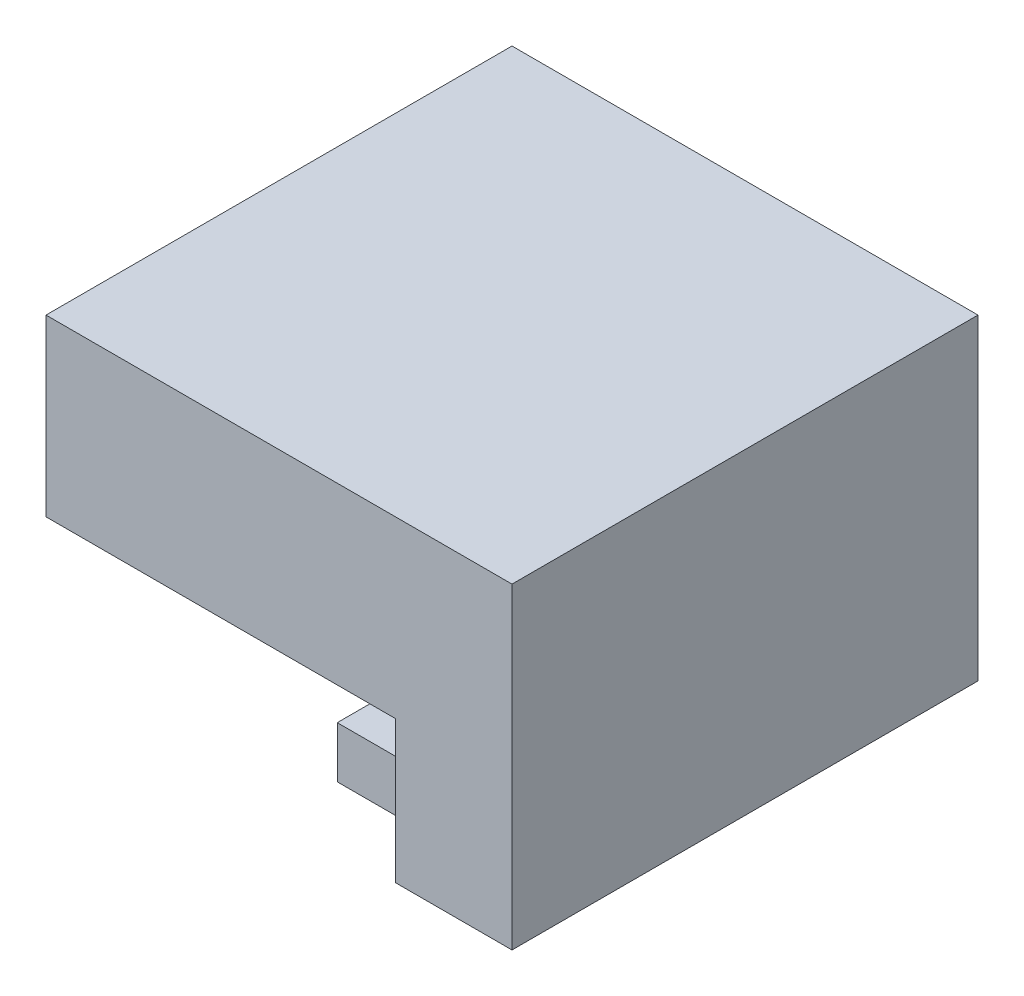
from build123d import *

# Parameters (mm, degrees)
SKETCH1_W           = 25.4
SKETCH1_H           = 9.525
BOSS_EXTRUDE1_DEPTH = 25.4
SKETCH2_W           = 6.35
SKETCH2_H           = 25.4
BOSS_EXTRUDE2_DEPTH = 7.747
SKETCH3_W           = 19.05
SKETCH3_H           = 2.794
BOSS_EXTRUDE3_DEPTH = 6.35
CUT_EXTRUDE1_DEPTH  = 6.35


with BuildPart() as part:
    # Sketch1 → Boss-Extrude1 (new body)
    with BuildSketch(Plane(origin=(0, 0, 0), x_dir=(0, 0, -1), z_dir=(1, 0, 0))):
        Rectangle(SKETCH1_W, SKETCH1_H)
    extrude(amount=BOSS_EXTRUDE1_DEPTH)

    # Sketch2 → Boss-Extrude2 (add)
    with BuildSketch(Plane.XZ.offset(4.7625)):
        with Locations((22.225, 0)):
            Rectangle(SKETCH2_W, SKETCH2_H)
    extrude(amount=BOSS_EXTRUDE2_DEPTH)

    # Sketch3 → Boss-Extrude3 (add)
    with BuildSketch(Plane.ZY.offset(-19.05)):
        with Locations((0, -11.1125)):
            Rectangle(SKETCH3_W, SKETCH3_H)
    extrude(amount=BOSS_EXTRUDE3_DEPTH)

    # Sketch4 → Cut-Extrude1 (cut)
    with BuildSketch(Plane.ZY):
        with BuildLine():
            Line((-7.62, -4.7625), (7.62, -4.7625))
            ThreePointArc((7.62, -4.7625), (0, 2.8575), (-7.62, -4.7625))
        make_face()
    extrude(amount=-CUT_EXTRUDE1_DEPTH, mode=Mode.SUBTRACT)


solid = part.part
